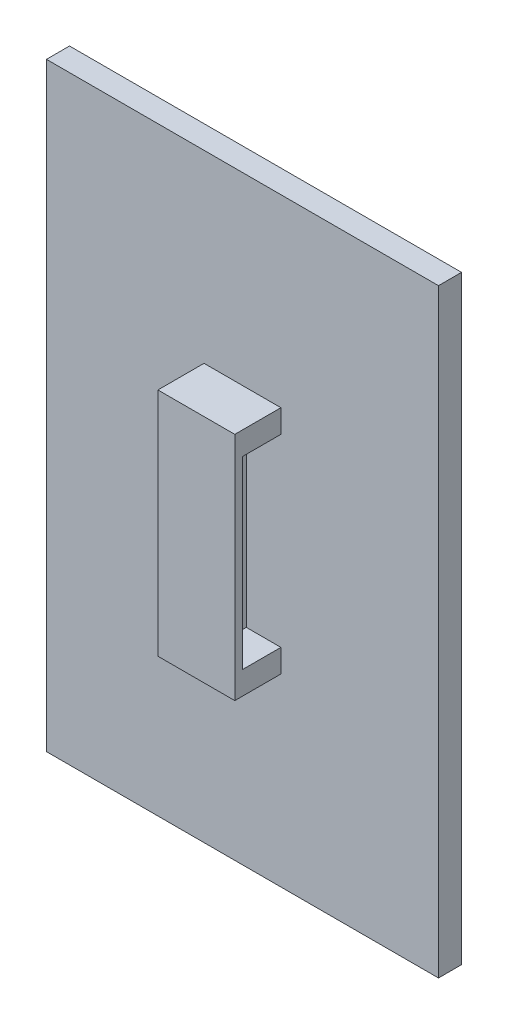
from build123d import *

# Parameters (mm, degrees)
SKETCH1_W           = 51
SKETCH1_H           = 78
BOSS_EXTRUDE1_DEPTH = 3
SKETCH2_W           = 10
SKETCH2_H           = 30
BOSS_EXTRUDE3_DEPTH = 6
SKETCH3_W           = 6
SKETCH3_H           = 24
CUT_EXTRUDE1_DEPTH  = 31.5
BOSS_EXTRUDE4_REACH = 53


with BuildPart() as part:
    # Sketch1 → Boss-Extrude1 (new body)
    with BuildSketch(Plane.XY):
        with Locations((-25.5, 39)):
            Rectangle(SKETCH1_W, SKETCH1_H)
    extrude(amount=BOSS_EXTRUDE1_DEPTH)

    # Sketch2 → Boss-Extrude3 (add)
    with BuildSketch(Plane.XY.offset(3)):
        with Locations((-25.5, 39)):
            Rectangle(SKETCH2_W, SKETCH2_H)
    extrude(amount=BOSS_EXTRUDE3_DEPTH)

    # Sketch3 → Cut-Extrude1 (cut, through all)
    with BuildSketch(Plane.ZY.offset(30.5)):
        with Locations((6, 39)):
            Rectangle(SKETCH3_W, SKETCH3_H)
    extrude(amount=-CUT_EXTRUDE1_DEPTH, mode=Mode.SUBTRACT)

    # Sketch5 → Boss-Extrude4 (add, up to next)
    with BuildSketch(Plane.XZ.offset(-51), mode=Mode.PRIVATE) as boss_extrude4_sk1:
        Polygon((-30.5, 9), (-20.5, 9), (-20.5, 8), (-25, 4), (-25, 3), (-26, 3), (-26, 4), (-30.5, 8), align=None)
    boss_extrude4_tool1 = extrude(boss_extrude4_sk1.sketch, amount=BOSS_EXTRUDE4_REACH, mode=Mode.PRIVATE) - part.part
    add(boss_extrude4_tool1.solids().sort_by_distance((-25.5, 51, 7.045455))[0])


solid = part.part
